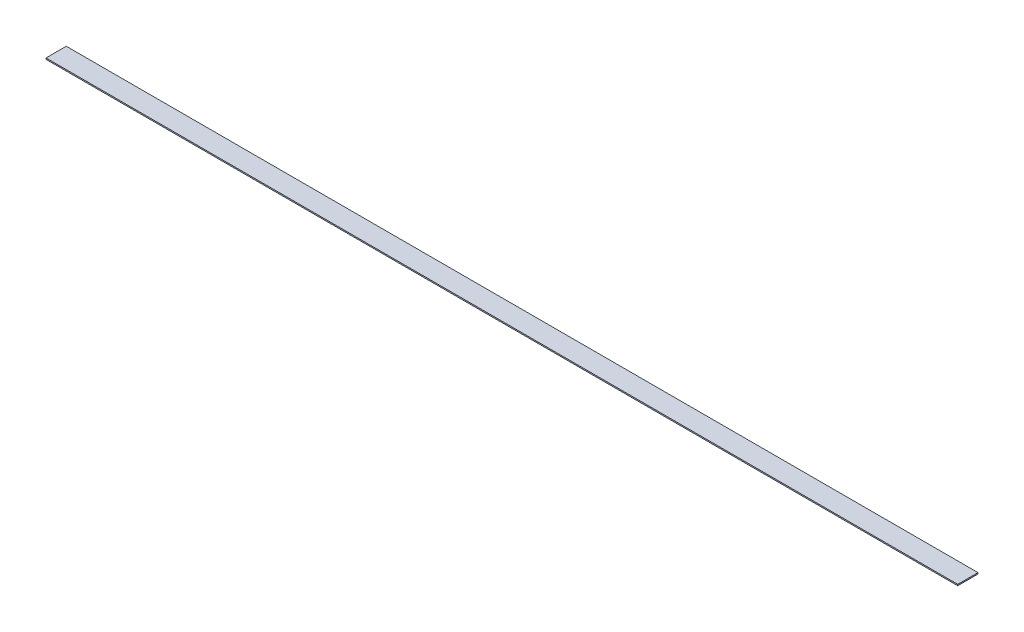
from build123d import *

# Parameters (mm, degrees)
SKETCH1_W           = 1143
SKETCH1_H           = 25.4
BOSS_EXTRUDE1_DEPTH = 1.5875


with BuildPart() as part:
    # Sketch1 → Boss-Extrude1 (new body)
    with BuildSketch(Plane(origin=(0, 0, 0), x_dir=(1, 0, 0), z_dir=(0, 1, 0))):
        with Locations((571.5, 12.7)):
            Rectangle(SKETCH1_W, SKETCH1_H)
    extrude(amount=BOSS_EXTRUDE1_DEPTH)


solid = part.part
